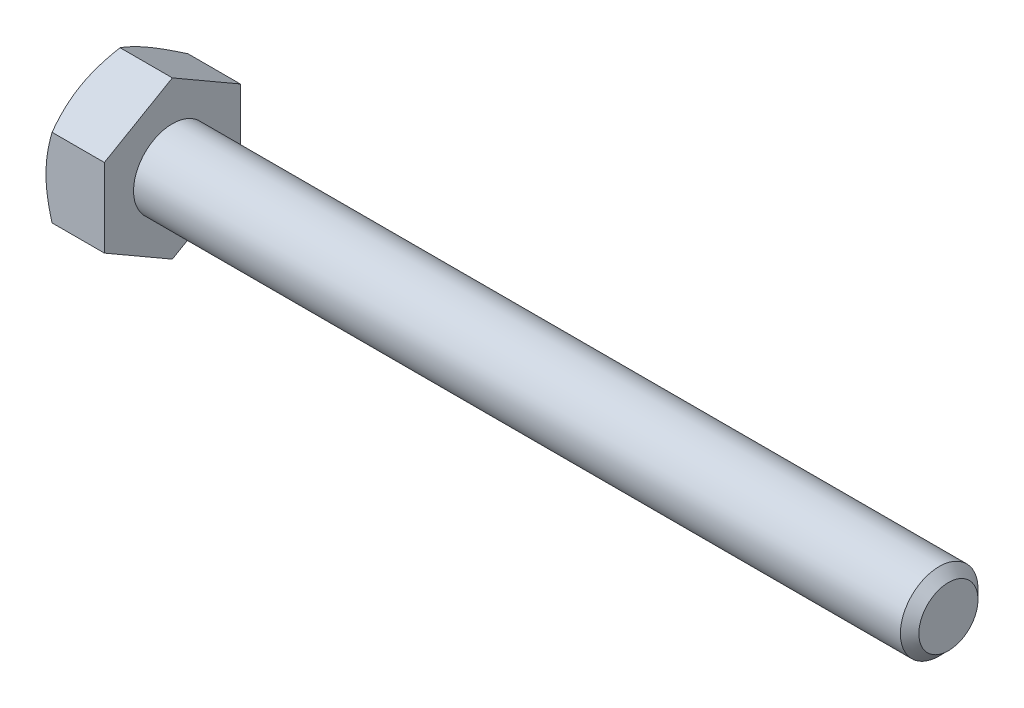
from build123d import *

# Parameters (mm, degrees)
BASEHEAD_DEPTH = 4.7752


with BuildPart() as part:
    # Sketch1 → BaseHead (new body)
    with BuildSketch(Plane(origin=(0, 0, 0), x_dir=(0, 0, -1), z_dir=(1, 0, 0))):
        Polygon((5.5626, 3.211568607), (5.5626, -3.211568607), (0, -6.423137215), (-5.5626, -3.211568607), (-5.5626, 3.211568607), (0, 6.423137215), align=None)
    extrude(amount=BASEHEAD_DEPTH)

    # BodySke → BaseBody (revolve)
    with BuildSketch(Plane.XY):
        Polygon((0, 0), (68.2752, 0), (68.2752, 2.41935), (67.51955, 3.175), (0, 3.175), align=None)
    revolve(axis=Axis((0, 0, 0), (1, 0, 0)))

    # Sketch3 → HeadChamfer (revolve, cut)
    with BuildSketch(Plane.XY):
        Polygon((0, 5.5626), (4.163005602, 12.773137215), (4.163005602, 19.123137215), (-12.7, 19.123137215), (-12.7, 5.5626), align=None)
    revolve(axis=Axis((0, 0, 0), (1, 0, 0)), mode=Mode.SUBTRACT)


solid = part.part
